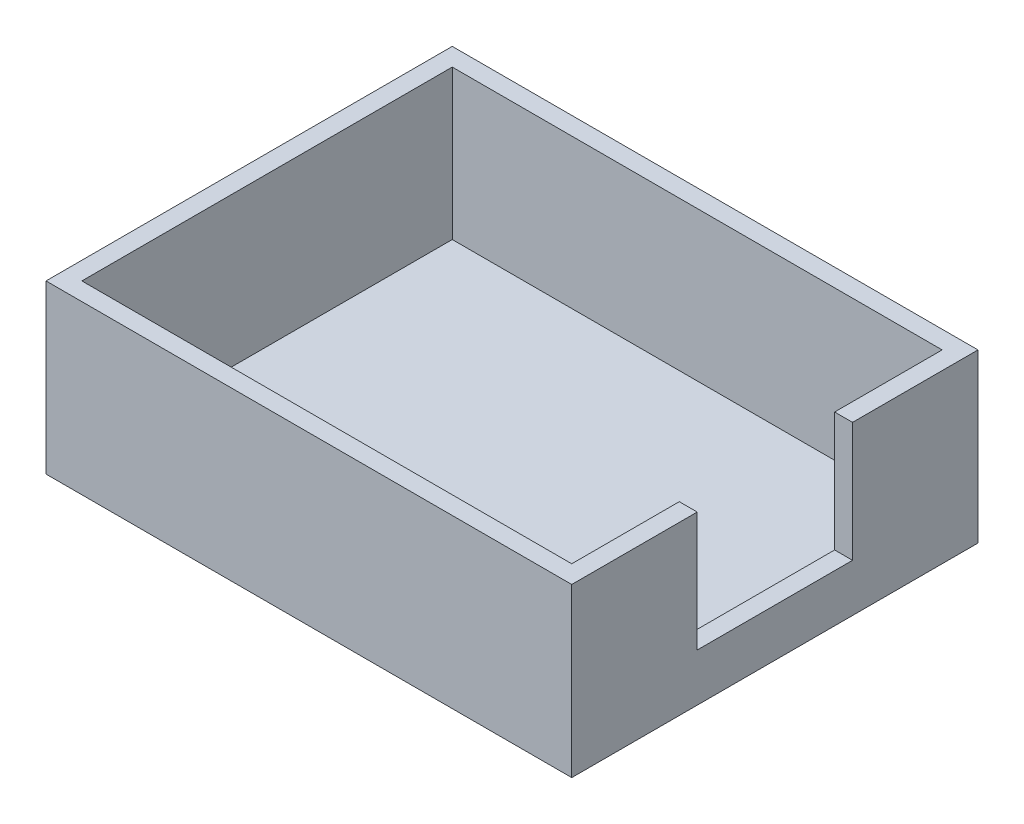
from build123d import *

# Parameters (mm, degrees)
ESQUISSE1_W             = 44
ESQUISSE1_H             = 34
BOSS_EXTRU_1_DEPTH      = 14
COQUE1_T                = -1.5
ESQUISSE2_W             = 1.5
ESQUISSE2_H             = 13
ENL_V_MAT_EXTRU_1_DEPTH = 10


with BuildPart() as part:
    # Esquisse1 → Boss.-Extru.1 (new body)
    with BuildSketch(Plane(origin=(0, 0, 0), x_dir=(1, 0, 0), z_dir=(0, 1, 0))):
        Rectangle(ESQUISSE1_W, ESQUISSE1_H)
    extrude(amount=BOSS_EXTRU_1_DEPTH)

    # Coque1
    coque1_openings = [part.faces().sort_by_distance(p)[0] for p in [
        (0, 14, 0),
    ]]
    offset(amount=COQUE1_T, openings=coque1_openings, kind=Kind.INTERSECTION)

    # Esquisse2 → Enlèv. mat.-Extru.1 (cut)
    with BuildSketch(Plane(origin=(0, 14, 0), x_dir=(1, 0, 0), z_dir=(0, 1, 0))):
        with Locations((21.25, 0)):
            Rectangle(ESQUISSE2_W, ESQUISSE2_H)
    extrude(amount=-ENL_V_MAT_EXTRU_1_DEPTH, mode=Mode.SUBTRACT)


solid = part.part
